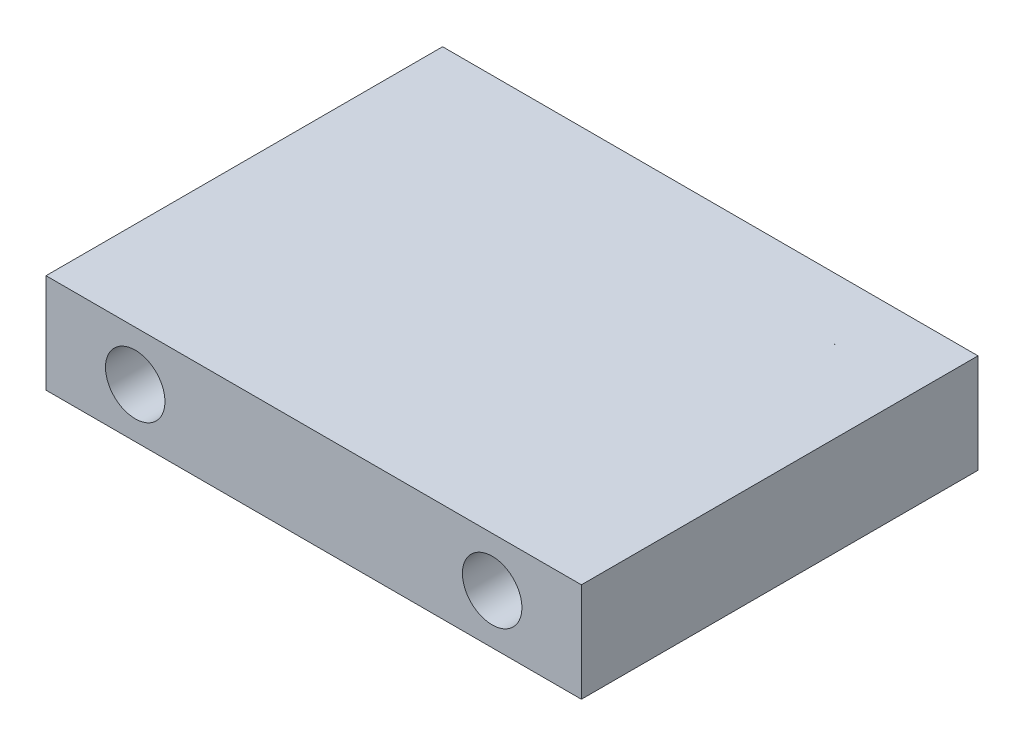
from build123d import *

# Parameters (mm, degrees)
SKETCH1_W               = 27
SKETCH1_H               = 20
BOSS_EXTRUDE1_DEPTH     = 5
CUT_EXTRUDE1_DEPTH      = 1000
CUT_EXTRUDE1_DEPTH_BACK = 1000
SKETCH2_R               = 1.5


with BuildPart() as part:
    # Sketch1 → Boss-Extrude1 (new body)
    with BuildSketch(Plane(origin=(0, 0, 0), x_dir=(1, 0, 0), z_dir=(0, 1, 0))):
        with Locations((13.5, 10)):
            Rectangle(SKETCH1_W, SKETCH1_H)
    extrude(amount=BOSS_EXTRUDE1_DEPTH)

    # Sketch2 → Cut-Extrude1 (cut, two sides: drawn at the far end of the back side and taken through both)
    with BuildSketch(Plane.XY.offset(-CUT_EXTRUDE1_DEPTH_BACK)):
        with Locations((4.5, 2.5)):
            Circle(SKETCH2_R)
        with Locations((22.5, 2.5)):
            Circle(SKETCH2_R)
    extrude(amount=CUT_EXTRUDE1_DEPTH + CUT_EXTRUDE1_DEPTH_BACK, mode=Mode.SUBTRACT)


solid = part.part
